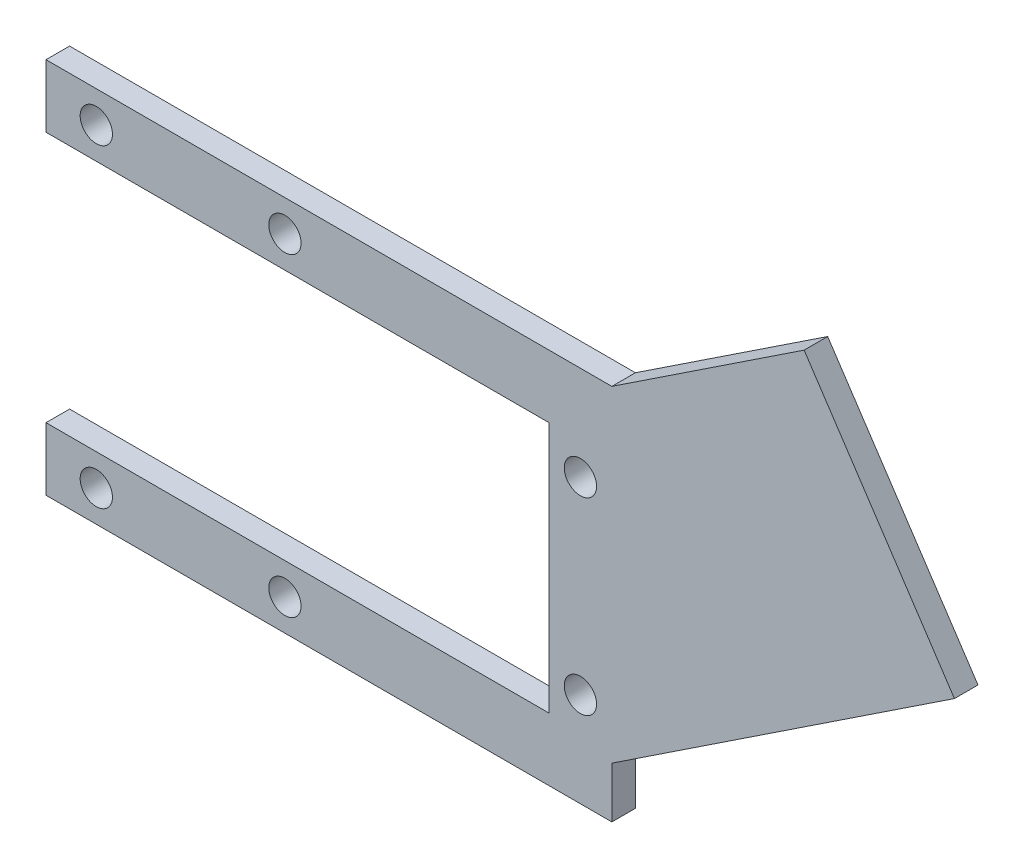
from build123d import *

# Parameters (mm, degrees)
SKETCH1_R           = 3.2639
BOSS_EXTRUDE1_DEPTH = 4.7625
CUT_EXTRUDE1_REACH  = 6.763
SKETCH2_R           = 3.2639


with BuildPart() as part:
    # Sketch1 → Boss-Extrude1 (new body)
    with BuildSketch(Plane.XY):
        Polygon((0, 0), (101.6, 0), (101.6, -50.8), (0, -50.8), (0, -63.5), (114.3, -63.5), (114.3, -53.215281422), (183.499345052, -7.322414016), (153.138236671, 38.457440977), (114.3, 12.7), (0, 12.7), align=None)
        with Locations((10.16, 6.35)):
            Circle(SKETCH1_R, mode=Mode.SUBTRACT)
        with Locations((48.26, 6.35)):
            Circle(SKETCH1_R, mode=Mode.SUBTRACT)
        with Locations((10.16, -57.15)):
            Circle(SKETCH1_R, mode=Mode.SUBTRACT)
        with Locations((48.26, -57.15)):
            Circle(SKETCH1_R, mode=Mode.SUBTRACT)
    extrude(amount=BOSS_EXTRUDE1_DEPTH)

    # Sketch2 → Cut-Extrude1 (cut, up to next)
    with BuildSketch(Plane.XY.offset(4.7625), mode=Mode.PRIVATE) as cut_extrude1_sk1:
        with Locations((107.95, -6.35)):
            Circle(SKETCH2_R)
    cut_extrude1_tool1 = extrude(cut_extrude1_sk1.sketch, amount=-CUT_EXTRUDE1_REACH, mode=Mode.PRIVATE) & part.part
    add(cut_extrude1_tool1.solids().sort_by_distance((107.95, -6.35, 4.7625))[0], mode=Mode.SUBTRACT)
    # Sketch2 → Cut-Extrude1 (cut, up to next)
    with BuildSketch(Plane.XY.offset(4.7625), mode=Mode.PRIVATE) as cut_extrude1_sk2:
        with Locations((107.95, -44.45)):
            Circle(SKETCH2_R)
    cut_extrude1_tool2 = extrude(cut_extrude1_sk2.sketch, amount=-CUT_EXTRUDE1_REACH, mode=Mode.PRIVATE) & part.part
    add(cut_extrude1_tool2.solids().sort_by_distance((107.95, -44.45, 4.7625))[0], mode=Mode.SUBTRACT)


solid = part.part
